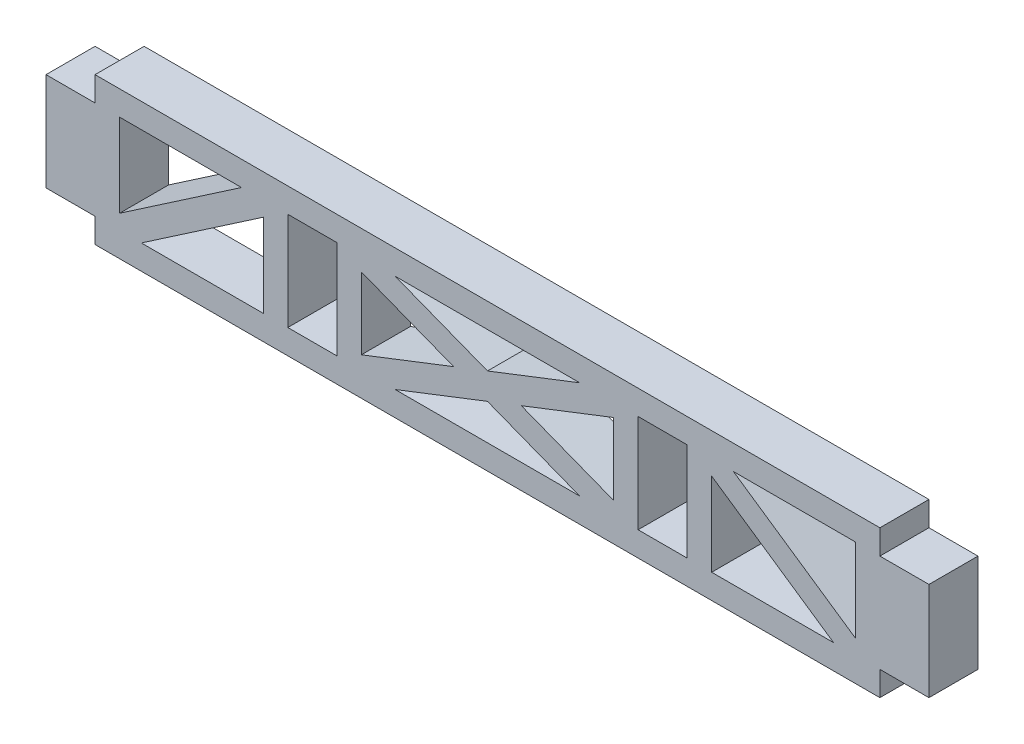
from build123d import *

# Parameters (mm, degrees)
SKETCH1_W           = 6.35
SKETCH1_H           = 12.7
BOSS_EXTRUDE1_DEPTH = 3.175
CUT_EXTRUDE1_DEPTH  = 7.35


with BuildPart() as part:
    # Sketch1 → Boss-Extrude1 (new body, symmetric)
    with BuildSketch(Plane.XY):
        Polygon((-50.8, -9.525), (50.8, -9.525), (50.8, -6.35), (57.15, -6.35), (57.15, 6.35), (50.8, 6.35), (50.8, 9.525), (-50.8, 9.525), (-50.8, 6.35), (-57.15, 6.35), (-57.15, -6.35), (-50.8, -6.35), align=None)
        with Locations((-22.675, 0)):
            Rectangle(SKETCH1_W, SKETCH1_H, mode=Mode.SUBTRACT)
        with Locations((22.675, 0)):
            Rectangle(SKETCH1_W, SKETCH1_H, mode=Mode.SUBTRACT)
    extrude(amount=BOSS_EXTRUDE1_DEPTH, both=True)

    # Sketch2 → Cut-Extrude1 (cut, through all)
    with BuildSketch(Plane.XY.offset(3.175)):
        Polygon((-31.840276407, 6.35), (-47.625, 6.35), (-47.625, -4.427741378), align=None)
        Polygon((-29.025, 4.427741378), (-44.809723593, -6.35), (-29.025, -6.35), align=None)
        Polygon((-16.325, -4.646633401), (-4.379127517, 0), (-16.325, 4.646633401), align=None)
        Polygon((-11.945872483, 6.35), (0, 1.703366599), (11.945872483, 6.35), align=None)
        Polygon((4.379127517, 0), (16.325, -4.646633401), (16.325, 4.646633401), align=None)
        Polygon((-11.945872483, -6.35), (11.945872483, -6.35), (0, -1.703366599), align=None)
        Polygon((44.809723593, -6.35), (29.025, 4.427741378), (29.025, -6.35), align=None)
        Polygon((47.625, 6.35), (31.840276407, 6.35), (47.625, -4.427741378), align=None)
    extrude(amount=-CUT_EXTRUDE1_DEPTH, mode=Mode.SUBTRACT)


solid = part.part
